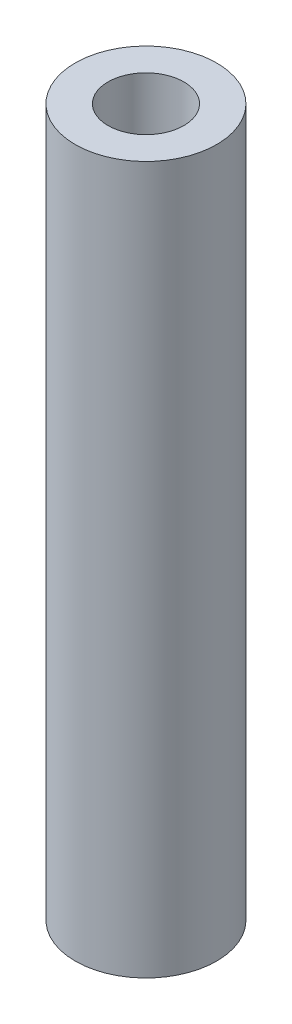
from build123d import *

# Parameters (mm, degrees)
SKETCH1_R      = 3.175
SKETCH1_R_2    = 1.7018
EXTRUDE1_DEPTH = 31.75


with BuildPart() as part:
    # Sketch1 → Extrude1 (new body)
    with BuildSketch(Plane(origin=(0, 0, 0), x_dir=(1, 0, 0), z_dir=(0, 1, 0))):
        Circle(SKETCH1_R)
        Circle(SKETCH1_R_2, mode=Mode.SUBTRACT)
    extrude(amount=EXTRUDE1_DEPTH)


solid = part.part
